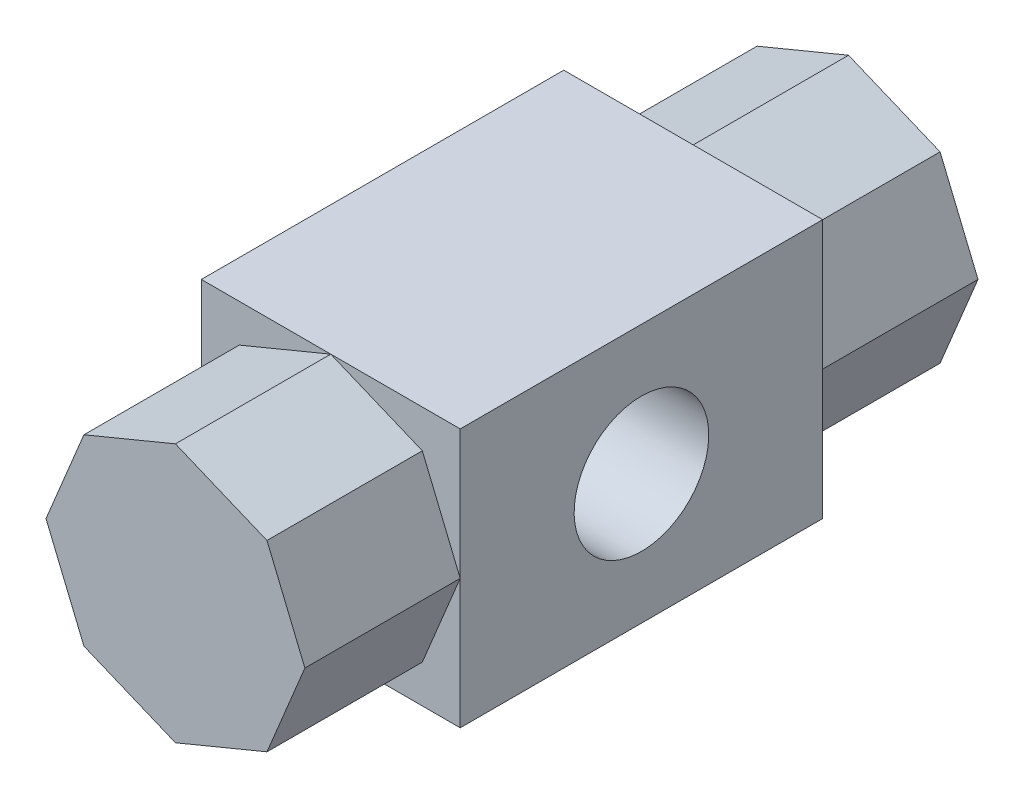
from build123d import *

# Parameters (mm, degrees)
BOSS_EXTRUDE1_DEPTH = 65
SKETCH1_W           = 50
SKETCH1_H           = 50
BOSS_EXTRUDE2_DEPTH = 35
SKETCH3_R           = 13
CUT_EXTRUDE1_DEPTH  = 70


with BuildPart() as part:
    # Sketch2 → Boss-Extrude1 (new body, symmetric)
    with BuildSketch(Plane.XY):
        Polygon((0, -25), (17.67766953, -17.67766953), (25, 0), (17.67766953, 17.67766953), (0, 25), (-17.67766953, 17.67766953), (-25, 0), (-17.67766953, -17.67766953), align=None)
    extrude(amount=BOSS_EXTRUDE1_DEPTH, both=True)

    # Sketch1 → Boss-Extrude2 (add, symmetric)
    with BuildSketch(Plane.XY):
        Rectangle(SKETCH1_W, SKETCH1_H)
    extrude(amount=BOSS_EXTRUDE2_DEPTH, both=True)

    # Sketch3 → Cut-Extrude1 (cut)
    with BuildSketch(Plane(origin=(25, 0, 0), x_dir=(0, 0, -1), z_dir=(1, 0, 0))):
        Circle(SKETCH3_R)
    extrude(amount=-CUT_EXTRUDE1_DEPTH, mode=Mode.SUBTRACT)


solid = part.part
